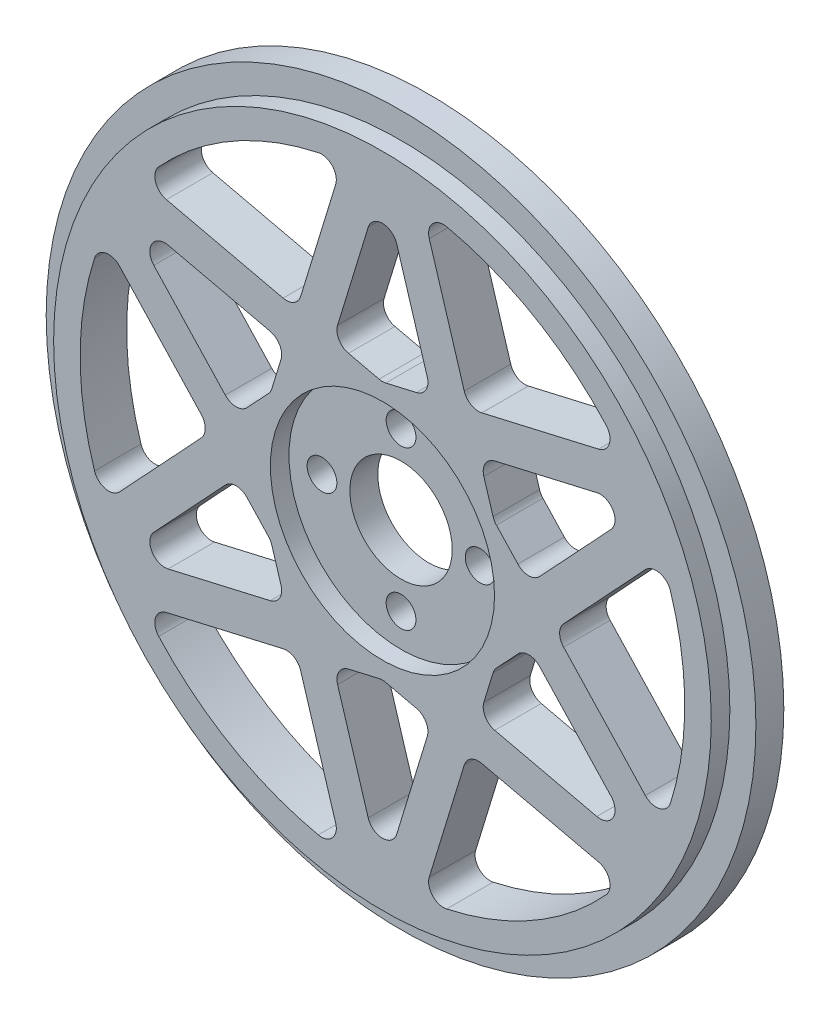
from build123d import *

# Parameters (mm, degrees)
SKETCH_1_R               = 38.15
EXTRUDE_1_DEPTH          = 3
SKETCH_2_R               = 35.35
EXTRUDE_2_DEPTH          = 2
SKETCH_6_R               = 5.5
CUT_EXTRUDE_2_DEPTH      = 6
SKETCH_7_R               = 32.5
SKETCH_7_R_2             = 13.5
CUT_EXTRUDE_3_DEPTH      = 1
CUT_EXTRUDE_3_DEPTH_BACK = 6
EXTRUDE_4_DEPTH          = 5
PATTERN_CIRCULAR_3_COUNT = 6
MIRROR_1_COPY_1_DEPTH    = 5
MIRROR_1_COPY_2_DEPTH    = 5
MIRROR_1_COPY_3_DEPTH    = 5
MIRROR_1_COPY_4_DEPTH    = 5
MIRROR_1_COPY_5_DEPTH    = 5
SKETCH_9_R               = 1.6
CUT_EXTRUDE_4_DEPTH      = 6
FILLET_3_R               = 1.6
FILLET_4_R               = 1.6
SKETCH_11_R              = 12.05
CUT_EXTRUDE_6_DEPTH      = 2


with BuildPart() as part:
    # ｽｹｯﾁ1 → ﾎﾞｽ - 押し出し1 (new body)
    with BuildSketch(Plane.XY):
        Circle(SKETCH_1_R)
    extrude(amount=EXTRUDE_1_DEPTH)

    # ｽｹｯﾁ2 → ﾎﾞｽ - 押し出し2 (add)
    with BuildSketch(Plane.XY.offset(3)):
        Circle(SKETCH_2_R)
    extrude(amount=EXTRUDE_2_DEPTH)

    # ｽｹｯﾁ6 → ｶｯﾄ - 押し出し2 (cut, through all)
    with BuildSketch(Plane.XY.offset(5)):
        Circle(SKETCH_6_R)
    extrude(amount=-CUT_EXTRUDE_2_DEPTH, mode=Mode.SUBTRACT)

    # ｽｹｯﾁ7 → ｶｯﾄ - 押し出し3 (cut, two sides)
    with BuildSketch(Plane.XY.offset(5)) as cut_extrude_3_sk:
        Circle(SKETCH_7_R)
        Circle(SKETCH_7_R_2, mode=Mode.SUBTRACT)
    extrude(amount=CUT_EXTRUDE_3_DEPTH, mode=Mode.SUBTRACT)
    extrude(cut_extrude_3_sk.sketch, amount=-CUT_EXTRUDE_3_DEPTH_BACK, mode=Mode.SUBTRACT)

    # ｽｹｯﾁ8 → ﾎﾞｽ - 押し出し4 (add)
    with BuildSketch(Plane.XY.offset(5)):
        with BuildLine():
            Line((-12.910378376, 3.946153846), (-4.268742546, 32.218439395))
            ThreePointArc((-4.268742546, 32.218439395), (-2.139009075, 32.429533456), (0, 32.5))
            Line((0, 32.5), (-6.281364189, 11.949663758))
            ThreePointArc((-6.281364189, 11.949663758), (-10.396864354, 8.611342032), (-12.910378376, 3.946153846))
        make_face()
    extrude_4 = extrude(amount=-EXTRUDE_4_DEPTH)

    # 円形ﾊﾟﾀｰﾝ3: ﾎﾞｽ - 押し出し4 ×6 about axis
    pattern_circular_3_axis = Axis((0, 0, 0), (0, 0, 1))
    for i in range(1, PATTERN_CIRCULAR_3_COUNT):
        add(extrude_4.rotate(pattern_circular_3_axis, i * 360 / PATTERN_CIRCULAR_3_COUNT))

    # ﾐﾗｰ1: ﾎﾞｽ - 押し出し4 across plane
    add(extrude_4.mirror(Plane(origin=(0, 0, 0), x_dir=(0, 0, 1), z_dir=(1, 0, 0))))

    # ﾐﾗｰ1 copy 1 sketch → ﾐﾗｰ1 copy 1 (add)
    with BuildSketch(Plane(origin=(0, 0, 5), x_dir=(-0.5, 0.866025404, 0), z_dir=(0, 0, 1))):
        with BuildLine():
            Line((-12.910378376, -3.946153846), (-4.268742546, -32.218439395))
            ThreePointArc((-4.268742546, -32.218439395), (-2.139009075, -32.429533456), (0, -32.5))
            Line((0, -32.5), (-6.281364189, -11.949663758))
            ThreePointArc((-6.281364189, -11.949663758), (-10.396864354, -8.611342032), (-12.910378376, -3.946153846))
        make_face()
    extrude(amount=-MIRROR_1_COPY_1_DEPTH)

    # ﾐﾗｰ1 copy 2 sketch → ﾐﾗｰ1 copy 2 (add)
    with BuildSketch(Plane(origin=(0, 0, 5), x_dir=(0.5, 0.866025404, 0), z_dir=(0, 0, 1))):
        with BuildLine():
            Line((-12.910378376, -3.946153846), (-4.268742546, -32.218439395))
            ThreePointArc((-4.268742546, -32.218439395), (-2.139009075, -32.429533456), (0, -32.5))
            Line((0, -32.5), (-6.281364189, -11.949663758))
            ThreePointArc((-6.281364189, -11.949663758), (-10.396864354, -8.611342032), (-12.910378376, -3.946153846))
        make_face()
    extrude(amount=-MIRROR_1_COPY_2_DEPTH)

    # ﾐﾗｰ1 copy 3 sketch → ﾐﾗｰ1 copy 3 (add)
    with BuildSketch(Plane.XY.offset(5)):
        with BuildLine():
            Line((-12.910378376, -3.946153846), (-4.268742546, -32.218439395))
            ThreePointArc((-4.268742546, -32.218439395), (-2.139009075, -32.429533456), (0, -32.5))
            Line((0, -32.5), (-6.281364189, -11.949663758))
            ThreePointArc((-6.281364189, -11.949663758), (-10.396864354, -8.611342032), (-12.910378376, -3.946153846))
        make_face()
    extrude(amount=-MIRROR_1_COPY_3_DEPTH)

    # ﾐﾗｰ1 copy 4 sketch → ﾐﾗｰ1 copy 4 (add)
    with BuildSketch(Plane(origin=(0, 0, 5), x_dir=(0.5, -0.866025404, 0), z_dir=(0, 0, 1))):
        with BuildLine():
            Line((-12.910378376, -3.946153846), (-4.268742546, -32.218439395))
            ThreePointArc((-4.268742546, -32.218439395), (-2.139009075, -32.429533456), (0, -32.5))
            Line((0, -32.5), (-6.281364189, -11.949663758))
            ThreePointArc((-6.281364189, -11.949663758), (-10.396864354, -8.611342032), (-12.910378376, -3.946153846))
        make_face()
    extrude(amount=-MIRROR_1_COPY_4_DEPTH)

    # ﾐﾗｰ1 copy 5 sketch → ﾐﾗｰ1 copy 5 (add)
    with BuildSketch(Plane(origin=(0, 0, 5), x_dir=(-0.5, -0.866025404, 0), z_dir=(0, 0, 1))):
        with BuildLine():
            Line((-12.910378376, -3.946153846), (-4.268742546, -32.218439395))
            ThreePointArc((-4.268742546, -32.218439395), (-2.139009075, -32.429533456), (0, -32.5))
            Line((0, -32.5), (-6.281364189, -11.949663758))
            ThreePointArc((-6.281364189, -11.949663758), (-10.396864354, -8.611342032), (-12.910378376, -3.946153846))
        make_face()
    extrude(amount=-MIRROR_1_COPY_5_DEPTH)

    # ｽｹｯﾁ9 → ｶｯﾄ - 押し出し4 (cut, through all)
    with BuildSketch(Plane.XY.offset(5)):
        with Locations((-8.5, 0)):
            Circle(SKETCH_9_R)
        with Locations((0, 8.5)):
            Circle(SKETCH_9_R)
        with Locations((8.5, 0)):
            Circle(SKETCH_9_R)
        with Locations((0, -8.5)):
            Circle(SKETCH_9_R)
    extrude(amount=-CUT_EXTRUDE_4_DEPTH, mode=Mode.SUBTRACT)

    # ﾌｨﾚｯﾄ3
    fillet_3_edges = [part.edges().sort_by_distance(p)[0] for p in [
        (11.999058751, 6.9276598, 2.5),
        (9.230036516, 15.986892202, 2.5),
        (4.268742546, 32.218439395, 2.5),
        (15.725247398, -2.932347892, 2.5),
        (15.725247398, 2.932347892, 2.5),
        (18.460073032, 0, 2.5),
        (11.999058751, -6.9276598, 2.5),
        (30.03635826, 12.41238021, 2.5),
        (10.402111466, -12.152289781, 2.5),
        (9.230036516, -15.986892202, 2.5),
        (25.767615714, -19.806059185, 2.5),
        (-5.323135932, 15.084637673, 2.5),
        (-9.230036516, 15.986892202, 2.5),
        (0, 13.8553196, 2.5),
        (-25.767615714, 19.806059185, 2.5),
        (4.268742546, -32.218439395, 2.5),
        (30.03635826, -12.41238021, 2.5),
        (28.145825623, -16.25, 2.5),
        (25.767615714, 19.806059185, 2.5),
        (28.145825623, 16.25, 2.5),
        (-4.268742546, 32.218439395, 2.5),
        (0, 32.5, 2.5),
        (10.402111466, 12.152289781, 2.5),
        (5.323135932, 15.084637673, 2.5),
    ]]
    fillet(fillet_3_edges, radius=FILLET_3_R)

    # ﾌｨﾚｯﾄ4
    fillet_4_edges = [part.edges().sort_by_distance(p)[0] for p in [
        (5.323135932, -15.084637673, 2.5),
        (0, -13.8553196, 2.5),
        (-10.402111466, -12.152289781, 2.5),
        (-5.323135932, -15.084637673, 2.5),
        (-9.230036516, -15.986892202, 2.5),
        (-11.999058751, -6.9276598, 2.5),
        (-4.268742546, -32.218439395, 2.5),
        (-15.725247398, 2.932347892, 2.5),
        (-15.725247398, -2.932347892, 2.5),
        (-18.460073032, 0, 2.5),
        (-11.999058751, 6.9276598, 2.5),
        (-30.03635826, -12.41238021, 2.5),
        (-30.03635826, 12.41238021, 2.5),
        (-28.145825623, 16.25, 2.5),
        (-10.402111466, 12.152289781, 2.5),
        (-25.767615714, -19.806059185, 2.5),
        (-28.145825623, -16.25, 2.5),
        (0, -32.5, 2.5),
    ]]
    fillet(fillet_4_edges, radius=FILLET_4_R)

    # ｽｹｯﾁ11 → ｶｯﾄ - 押し出し6 (cut)
    with BuildSketch(Plane.XY.offset(5)):
        Circle(SKETCH_11_R)
    extrude(amount=-CUT_EXTRUDE_6_DEPTH, mode=Mode.SUBTRACT)


solid = part.part
